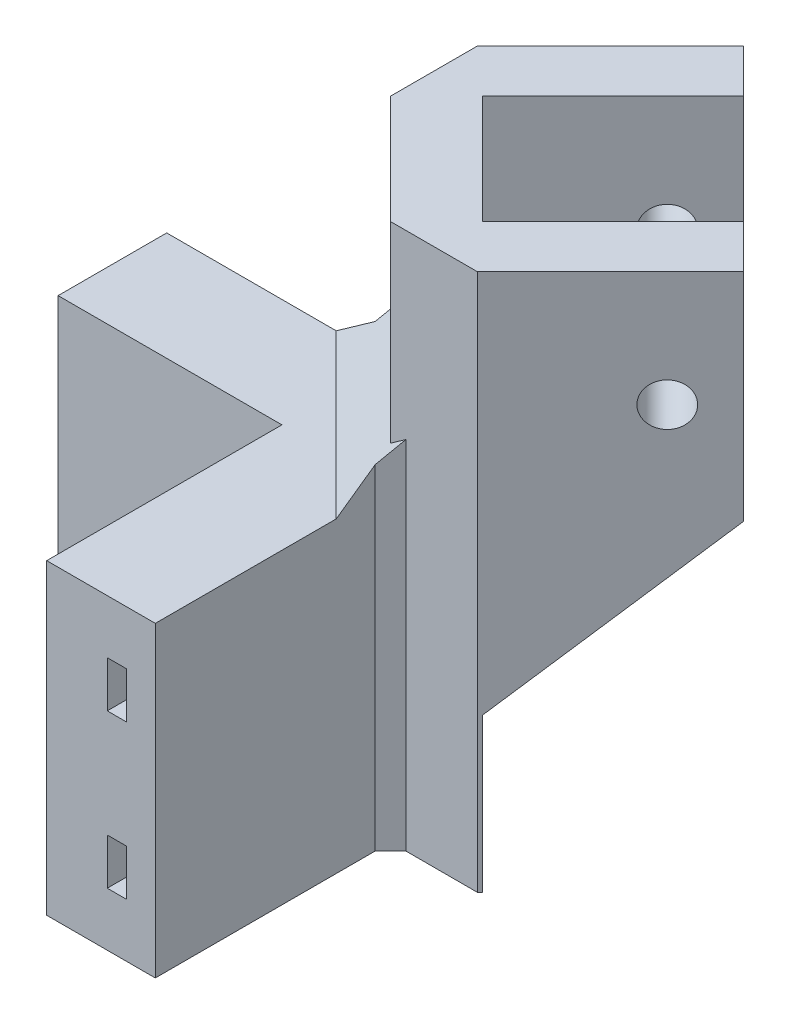
from build123d import *

# Parameters (mm, degrees)
BOSS_EXTRUDE1_DEPTH     = 30
SKETCH2_R               = 2.8
CUT_EXTRUDE1_DEPTH      = 65
CUT_EXTRUDE2_DEPTH      = 65
BOSS_EXTRUDE2_DEPTH     = 40
SKETCH9_W               = 55.910316486
SKETCH9_H               = 20
CUT_EXTRUDE4_DEPTH      = 40
CUT_EXTRUDE5_DEPTH      = 40
CHAMFER1_SIZE           = 5
CUT_EXTRUDE6_DEPTH      = 3
CUT_EXTRUDE6_DEPTH_BACK = 3
CUT_EXTRUDE7_DEPTH      = 3
CUT_EXTRUDE7_DEPTH_BACK = 3
SKETCH14_W              = 8
SKETCH14_H              = 30
BOSS_EXTRUDE3_DEPTH     = 2
CUT_EXTRUDE8_DEPTH      = 22
CHAMFER2_SIZE           = 2


with BuildPart() as part:
    # Sketch1 → Boss-Extrude1 (new body)
    with BuildSketch(Plane(origin=(0, 0, 0), x_dir=(1, 0, 0), z_dir=(0, 1, 0))):
        Polygon((-69, -54.857864376), (-54.857864376, -69), (-39.30151519, -53.443650814), (-33.644660941, -59.100505063), (-49.544155877, -75), (-75, -75), (-75, -49.544155877), (-59.100505063, -33.644660941), (-53.443650814, -39.30151519), align=None)
    extrude(amount=BOSS_EXTRUDE1_DEPTH)

    # Sketch2 → Cut-Extrude1 (cut)
    with BuildSketch(Plane(origin=(12.727922061, 0, 12.727922061), x_dir=(0.707106781, 0, -0.707106781), z_dir=(0.707106781, 0, 0.707106781))):
        with Locations((-70.580735804, 15)):
            Circle(SKETCH2_R)
    extrude(amount=-CUT_EXTRUDE1_DEPTH, mode=Mode.SUBTRACT)

    # Sketch4 → Cut-Extrude2 (cut)
    with BuildSketch(Plane.XZ):
        Polygon((-60.857864376, 75), (-75, 60.857864376), (-82.434342637, 68.292207014), (-68.292207014, 82.434342637), align=None)
    extrude(amount=-CUT_EXTRUDE2_DEPTH, mode=Mode.SUBTRACT)

    # Sketch6 → Boss-Extrude2 (add)
    with BuildSketch(Plane.XZ):
        Polygon((-60.857864376, 75), (-60.857864376, 105.632615689), (-75, 105.632615689), (-75, 75), (-104.149605391, 75), (-104.149605391, 60.857864376), (-75, 60.857864376), (-75, 49.544155877), (-59.100505063, 33.644660941), (-53.443650814, 39.30151519), (-69, 54.857864376), (-54.857864376, 69), (-39.30151519, 53.443650814), (-33.644660941, 59.100505063), (-49.544155877, 75), align=None)
    extrude(amount=BOSS_EXTRUDE2_DEPTH)

    # Sketch9 → Cut-Extrude4 (cut)
    with BuildSketch(Plane(origin=(-61.928932188, 0, 61.928932188), x_dir=(-0.707106781, 0, -0.707106781), z_dir=(0.707106781, 0, -0.707106781))):
        with Locations((0, -30)):
            Rectangle(SKETCH9_W, SKETCH9_H)
    extrude(amount=CUT_EXTRUDE4_DEPTH, mode=Mode.SUBTRACT)

    # Sketch10 → Cut-Extrude5 (cut)
    with BuildSketch(Plane(origin=(12.727922061, 0, 12.727922061), x_dir=(0.707106781, 0, -0.707106781), z_dir=(0.707106781, 0, 0.707106781))):
        Polygon((-87.580735804, -20), (-65.580735804, 0), (-65.580735804, -20), align=None)
    extrude(amount=-CUT_EXTRUDE5_DEPTH, mode=Mode.SUBTRACT)

    # Chamfer1
    chamfer1_edges = [part.edges().sort_by_distance(p)[0] for p in [
        (-67.928932188, 0, 67.928932188),
    ]]
    chamfer(chamfer1_edges, length=CHAMFER1_SIZE)

    # Sketch12 → Cut-Extrude6 (cut, two sides)
    with BuildSketch(Plane(origin=(0, -10, 0), x_dir=(1, 0, 0), z_dir=(0, 1, 0))) as cut_extrude6_sk:
        with BuildLine():
            Line((-75, -67.114451053), (-110.706734673, -67.114451053))
            Line((-110.706734673, -67.114451053), (-110.706734673, -64.614451053))
            Line((-110.706734673, -64.614451053), (-75, -64.614451053))
            ThreePointArc((-75, -64.614451053), (-67.656307913, -67.656307913), (-64.614451053, -75))
            Line((-64.614451053, -75), (-64.614451053, -107.388255064))
            Line((-64.614451053, -107.388255064), (-67.114451053, -107.388255064))
            Line((-67.114451053, -107.388255064), (-67.114451053, -75))
            ThreePointArc((-67.114451053, -75), (-69.424074866, -69.424074866), (-75, -67.114451053))
        make_face()
    extrude(amount=CUT_EXTRUDE6_DEPTH, mode=Mode.SUBTRACT)
    extrude(cut_extrude6_sk.sketch, amount=-CUT_EXTRUDE6_DEPTH_BACK, mode=Mode.SUBTRACT)

    # Sketch13 → Cut-Extrude7 (cut, two sides)
    with BuildSketch(Plane(origin=(0, -30, 0), x_dir=(1, 0, 0), z_dir=(0, 1, 0))) as cut_extrude7_sk:
        with BuildLine():
            Line((-110.706734673, -67.114451053), (-75, -67.114451053))
            ThreePointArc((-75, -67.114451053), (-69.424074866, -69.424074866), (-67.114451053, -75))
            Line((-67.114451053, -75), (-67.114451053, -107.388255064))
            Line((-67.114451053, -107.388255064), (-64.614451053, -107.388255064))
            Line((-64.614451053, -107.388255064), (-64.614451053, -75))
            ThreePointArc((-64.614451053, -75), (-67.656307913, -67.656307913), (-75, -64.614451053))
            Line((-75, -64.614451053), (-110.706734673, -64.614451053))
            Line((-110.706734673, -64.614451053), (-110.706734673, -67.114451053))
        make_face()
    extrude(amount=CUT_EXTRUDE7_DEPTH, mode=Mode.SUBTRACT)
    extrude(cut_extrude7_sk.sketch, amount=-CUT_EXTRUDE7_DEPTH_BACK, mode=Mode.SUBTRACT)

    # Sketch14 → Boss-Extrude3 (add)
    with BuildSketch(Plane(origin=(-46.372583002, 0, 46.372583002), x_dir=(-0.707106781, 0, -0.707106781), z_dir=(0.707106781, 0, -0.707106781))):
        with Locations((-14, 15)):
            Rectangle(SKETCH14_W, SKETCH14_H)
        with Locations((14, 15)):
            Rectangle(SKETCH14_W, SKETCH14_H)
    extrude(amount=BOSS_EXTRUDE3_DEPTH)

    # Sketch15 → Cut-Extrude8 (cut)
    with BuildSketch(Plane(origin=(-20.983069232, 32.641995196, 20.983069232), x_dir=(0.879633819, 0.400113768, 0.257202871), z_dir=(0.475651494, -0.739940073, -0.475651494))):
        Polygon((-16.653515894, 59.58496844), (-53.507538304, 34.603245183), (-43.108288721, 19.261862476), (-6.254266311, 44.243585732), align=None)
    extrude(amount=CUT_EXTRUDE8_DEPTH, mode=Mode.SUBTRACT)

    # Chamfer2
    chamfer2_edges = [part.edges().sort_by_distance(p)[0] for p in [
        (-60.857864376, -17.5, 75),
        (-75, -17.5, 60.857864376),
    ]]
    chamfer(chamfer2_edges, length=CHAMFER2_SIZE)


solid = part.part
